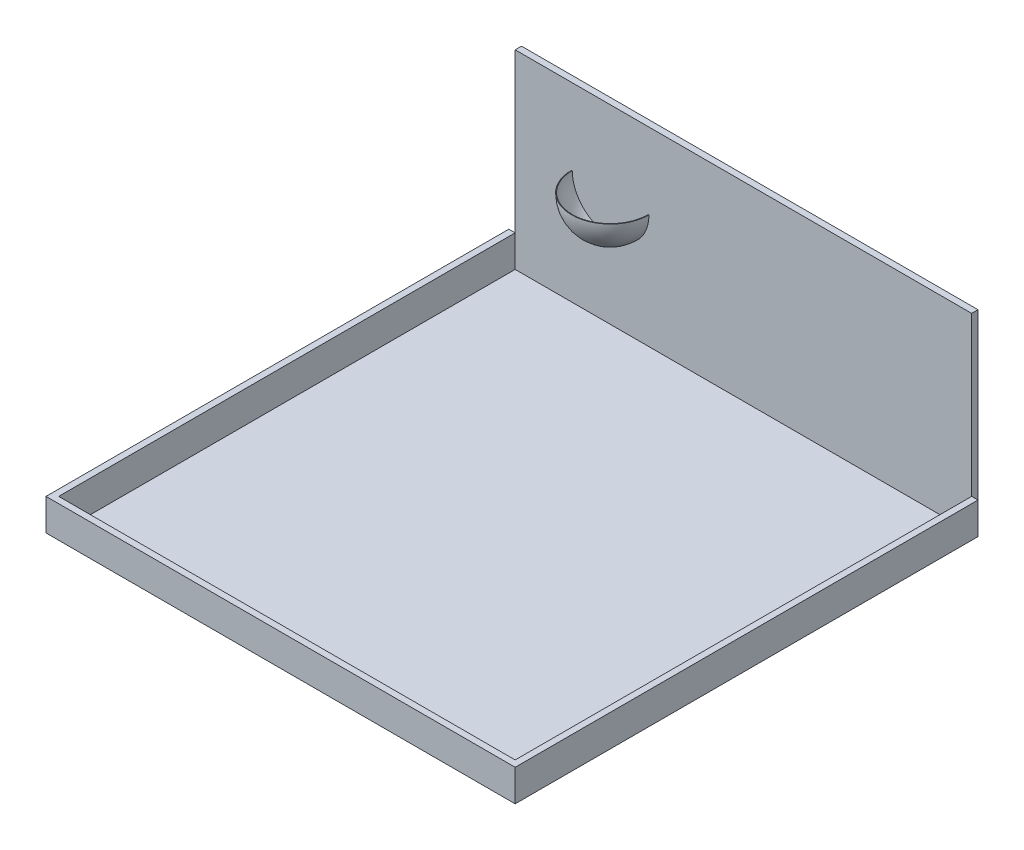
from build123d import *

# Parameters (mm, degrees)
SKETCH1_W           = 1828.8
SKETCH1_H           = 1828.8
BOSS_EXTRUDE1_DEPTH = 25.4
SKETCH4_W           = 1828.8
SKETCH4_H           = 25.4
BOSS_EXTRUDE2_DEPTH = 762
BOSS_EXTRUDE3_DEPTH = 127
REVOLVE1_ANGLE      = 180


with BuildPart() as part:
    # Sketch1 → Boss-Extrude1 (new body)
    with BuildSketch(Plane(origin=(0, 0, 0), x_dir=(1, 0, 0), z_dir=(0, 1, 0))):
        with Locations((914.4, 914.4)):
            Rectangle(SKETCH1_W, SKETCH1_H)
    extrude(amount=BOSS_EXTRUDE1_DEPTH)


with BuildPart() as body_2:
    # Sketch4 → Boss-Extrude2 (new body)
    with BuildSketch(Plane(origin=(0, 25.4, 0), x_dir=(1, 0, 0), z_dir=(0, 1, 0))):
        with Locations((914.4, 1841.5)):
            Rectangle(SKETCH4_W, SKETCH4_H)
    extrude(amount=BOSS_EXTRUDE2_DEPTH)

    # Sketch6 → Revolve1 (revolve)
    with BuildSketch(Plane.XY.offset(-1828.8)):
        with BuildLine():
            Line((226.06, 482.6), (228.6, 482.6))
            ThreePointArc((228.6, 482.6), (273.236926547, 374.836926547), (381, 330.2))
            Line((381, 330.2), (381, 327.66))
            ThreePointArc((381, 327.66), (271.440875323, 373.040875323), (226.06, 482.6))
        make_face()
    revolve(axis=Axis((381, 330.2, -1828.8), (0, 1, 0)), revolution_arc=REVOLVE1_ANGLE)


with BuildPart() as body_3:
    # Sketch5 → Boss-Extrude3 (new body)
    with BuildSketch(Plane(origin=(0, 25.4, 0), x_dir=(1, 0, 0), z_dir=(0, 1, 0))):
        Polygon((0, 1828.8), (-25.4, 1828.8), (-25.4, -25.4), (1854.2, -25.4), (1854.2, 1828.8), (1828.8, 1828.8), (1828.8, 0), (0, 0), align=None)
    extrude(amount=BOSS_EXTRUDE3_DEPTH)


solid = Compound([part.part, body_2.part, body_3.part])
